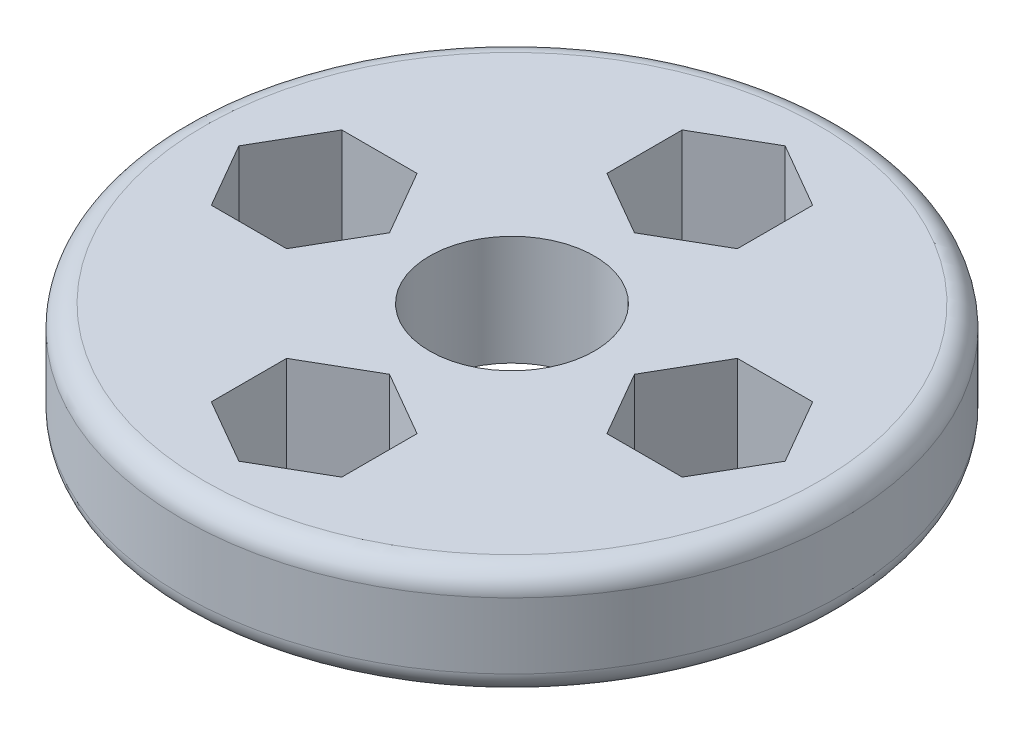
from build123d import *

# Parameters (mm, degrees)
SKETCH1_R           = 30
BOSS_EXTRUDE1_DEPTH = 10
SKETCH2_R           = 7.5
CUT_EXTRUDE1_DEPTH  = 11
FILLET1_R           = 2
CUT_EXTRUDE2_DEPTH  = 11
CIRPATTERN1_COUNT   = 4


with BuildPart() as part:
    # Sketch1 → Boss-Extrude1 (new body)
    with BuildSketch(Plane(origin=(0, 0, 0), x_dir=(1, 0, 0), z_dir=(0, 1, 0))):
        Circle(SKETCH1_R)
    extrude(amount=BOSS_EXTRUDE1_DEPTH)

    # Sketch2 → Cut-Extrude1 (cut, through all)
    with BuildSketch(Plane(origin=(0, 10, 0), x_dir=(1, 0, 0), z_dir=(0, 1, 0))):
        Circle(SKETCH2_R)
    extrude(amount=-CUT_EXTRUDE1_DEPTH, mode=Mode.SUBTRACT)

    # Fillet1
    fillet1_edges = [part.edges().sort_by_distance(p)[0] for p in [
        (-30, 0, 0),
        (-30, 10, 0),
    ]]
    fillet(fillet1_edges, radius=FILLET1_R)

    # Sketch3 → Cut-Extrude2 (cut, through all)
    with BuildSketch(Plane(origin=(0, 10, 0), x_dir=(1, 0, 0), z_dir=(0, 1, 0))):
        Polygon((0, 11.151208395), (5.936478896, 14.578636083), (5.936478896, 21.43349146), (0, 24.860919148), (-5.936478896, 21.43349146), (-5.936478896, 14.578636083), align=None)
    cut_extrude2 = extrude(amount=-CUT_EXTRUDE2_DEPTH, mode=Mode.SUBTRACT)

    # CirPattern1: Cut-Extrude2 ×4 about axis
    cirpattern1_axis = Axis((0, 0, 0), (0, 1, 0))
    for i in range(1, CIRPATTERN1_COUNT):
        add(cut_extrude2.rotate(cirpattern1_axis, i * 360 / CIRPATTERN1_COUNT), mode=Mode.SUBTRACT)


solid = part.part
